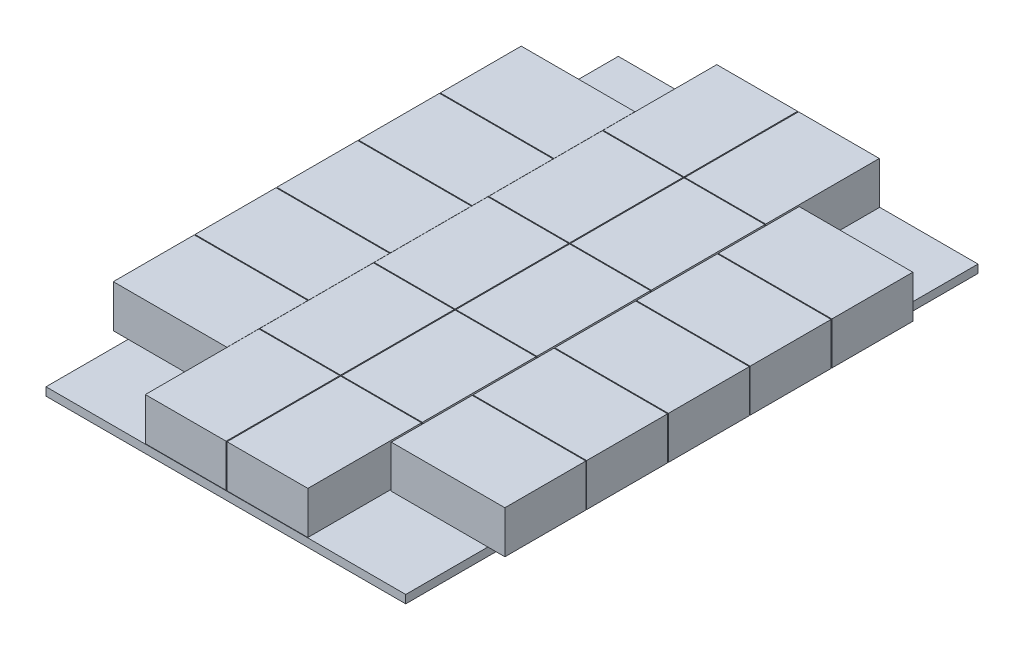
from build123d import *

# Parameters (mm, degrees)
SKETCH1_W                     = 220
SKETCH1_H                     = 350
BOSS_EXTRUDE1_DEPTH           = 5
SKETCH2_W                     = 49.4
SKETCH2_H                     = 69.5
BOSS_EXTRUDE2_DEPTH           = 26
LPATTERN1_COUNT               = 2
LPATTERN1_PITCH               = 50
LPATTERN3_COUNT               = 3
LPATTERN3_PITCH               = 70
LPATTERN3_COPY_1_SKETCH_W     = 49.4
LPATTERN3_COPY_1_SKETCH_H     = 69.5
LPATTERN3_COPY_1_DEPTH        = 26
LPATTERN3_COPY_2_SKETCH_W     = 49.4
LPATTERN3_COPY_2_SKETCH_H     = 69.5
LPATTERN3_COPY_2_DEPTH        = 26
LPATTERN3_COL_COUNT           = 3
LPATTERN3_COL_PITCH           = 70
LPATTERN3_COL_COPY_1_SKETCH_W = 49.4
LPATTERN3_COL_COPY_1_SKETCH_H = 69.5
LPATTERN3_COL_COPY_1_DEPTH    = 26
LPATTERN3_COL_COPY_2_SKETCH_W = 49.4
LPATTERN3_COL_COPY_2_SKETCH_H = 69.5
LPATTERN3_COL_COPY_2_DEPTH    = 26
SKETCH4_W                     = 69.5
SKETCH4_H                     = 49.5
BOSS_EXTRUDE3_DEPTH           = 26
LPATTERN4_COUNT               = 3
LPATTERN4_PITCH               = 50
LPATTERN4_COL_COUNT           = 3
LPATTERN4_COL_PITCH           = 50
LPATTERN5_COUNT               = 2
LPATTERN5_PITCH               = 170
LPATTERN5_COPY_1_SKETCH_W     = 69.5
LPATTERN5_COPY_1_SKETCH_H     = 49.5
LPATTERN5_COPY_1_DEPTH        = 26
LPATTERN5_COPY_2_SKETCH_W     = 69.5
LPATTERN5_COPY_2_SKETCH_H     = 49.5
LPATTERN5_COPY_2_DEPTH        = 26
LPATTERN5_COPY_3_SKETCH_W     = 69.5
LPATTERN5_COPY_3_SKETCH_H     = 49.5
LPATTERN5_COPY_3_DEPTH        = 26
LPATTERN5_COPY_4_SKETCH_W     = 69.5
LPATTERN5_COPY_4_SKETCH_H     = 49.5
LPATTERN5_COPY_4_DEPTH        = 26


with BuildPart() as part:
    # Sketch1 → Boss-Extrude1 (new body)
    with BuildSketch(Plane(origin=(0, 0, 0), x_dir=(1, 0, 0), z_dir=(0, 1, 0))):
        Rectangle(SKETCH1_W, SKETCH1_H)
    extrude(amount=BOSS_EXTRUDE1_DEPTH)

    # Sketch2 → Boss-Extrude2 (add)
    with BuildSketch(Plane(origin=(0, 5, 0), x_dir=(1, 0, 0), z_dir=(0, 1, 0))):
        with Locations((-24.8, 0)):
            Rectangle(SKETCH2_W, SKETCH2_H)
    boss_extrude2 = extrude(amount=BOSS_EXTRUDE2_DEPTH)

    # LPattern1: Boss-Extrude2 ×2
    with Locations(*[(i * LPATTERN1_PITCH, 0, 0) for i in range(1, LPATTERN1_COUNT)]):
        add(boss_extrude2)

    # LPattern3: Boss-Extrude2 ×3
    with Locations(*[(0, 0, -i * LPATTERN3_PITCH) for i in range(1, LPATTERN3_COUNT)]):
        add(boss_extrude2)

    # LPattern3 copy 1 sketch → LPattern3 copy 1 (add)
    with BuildSketch(Plane(origin=(50, 5, -70), x_dir=(1, 0, 0), z_dir=(0, 1, 0))):
        with Locations((-24.8, 0)):
            Rectangle(LPATTERN3_COPY_1_SKETCH_W, LPATTERN3_COPY_1_SKETCH_H)
    extrude(amount=LPATTERN3_COPY_1_DEPTH)

    # LPattern3 copy 2 sketch → LPattern3 copy 2 (add)
    with BuildSketch(Plane(origin=(50, 5, -140), x_dir=(1, 0, 0), z_dir=(0, 1, 0))):
        with Locations((-24.8, 0)):
            Rectangle(LPATTERN3_COPY_2_SKETCH_W, LPATTERN3_COPY_2_SKETCH_H)
    extrude(amount=LPATTERN3_COPY_2_DEPTH)

    # LPattern3 col: Boss-Extrude2 ×3
    with Locations(*[(0, 0, i * LPATTERN3_COL_PITCH) for i in range(1, LPATTERN3_COL_COUNT)]):
        add(boss_extrude2)

    # LPattern3 col copy 1 sketch → LPattern3 col copy 1 (add)
    with BuildSketch(Plane(origin=(50, 5, 70), x_dir=(1, 0, 0), z_dir=(0, 1, 0))):
        with Locations((-24.8, 0)):
            Rectangle(LPATTERN3_COL_COPY_1_SKETCH_W, LPATTERN3_COL_COPY_1_SKETCH_H)
    extrude(amount=LPATTERN3_COL_COPY_1_DEPTH)

    # LPattern3 col copy 2 sketch → LPattern3 col copy 2 (add)
    with BuildSketch(Plane(origin=(50, 5, 140), x_dir=(1, 0, 0), z_dir=(0, 1, 0))):
        with Locations((-24.8, 0)):
            Rectangle(LPATTERN3_COL_COPY_2_SKETCH_W, LPATTERN3_COL_COPY_2_SKETCH_H)
    extrude(amount=LPATTERN3_COL_COPY_2_DEPTH)

    # Sketch4 → Boss-Extrude3 (add)
    with BuildSketch(Plane(origin=(0, 5, 0), x_dir=(1, 0, 0), z_dir=(0, 1, 0))):
        with Locations((-84.35, 0)):
            Rectangle(SKETCH4_W, SKETCH4_H)
    boss_extrude3 = extrude(amount=BOSS_EXTRUDE3_DEPTH)

    # LPattern4: Boss-Extrude3 ×3
    with Locations(*[(0, 0, i * LPATTERN4_PITCH) for i in range(1, LPATTERN4_COUNT)]):
        add(boss_extrude3)

    # LPattern4 col: Boss-Extrude3 ×3
    with Locations(*[(0, 0, -i * LPATTERN4_COL_PITCH) for i in range(1, LPATTERN4_COL_COUNT)]):
        add(boss_extrude3)

    # LPattern5: Boss-Extrude3 ×2
    with Locations(*[(i * LPATTERN5_PITCH, 0, 0) for i in range(1, LPATTERN5_COUNT)]):
        add(boss_extrude3)

    # LPattern5 copy 1 sketch → LPattern5 copy 1 (add)
    with BuildSketch(Plane(origin=(170, 5, 50), x_dir=(1, 0, 0), z_dir=(0, 1, 0))):
        with Locations((-84.35, 0)):
            Rectangle(LPATTERN5_COPY_1_SKETCH_W, LPATTERN5_COPY_1_SKETCH_H)
    extrude(amount=LPATTERN5_COPY_1_DEPTH)

    # LPattern5 copy 2 sketch → LPattern5 copy 2 (add)
    with BuildSketch(Plane(origin=(170, 5, 100), x_dir=(1, 0, 0), z_dir=(0, 1, 0))):
        with Locations((-84.35, 0)):
            Rectangle(LPATTERN5_COPY_2_SKETCH_W, LPATTERN5_COPY_2_SKETCH_H)
    extrude(amount=LPATTERN5_COPY_2_DEPTH)

    # LPattern5 copy 3 sketch → LPattern5 copy 3 (add)
    with BuildSketch(Plane(origin=(170, 5, -50), x_dir=(1, 0, 0), z_dir=(0, 1, 0))):
        with Locations((-84.35, 0)):
            Rectangle(LPATTERN5_COPY_3_SKETCH_W, LPATTERN5_COPY_3_SKETCH_H)
    extrude(amount=LPATTERN5_COPY_3_DEPTH)

    # LPattern5 copy 4 sketch → LPattern5 copy 4 (add)
    with BuildSketch(Plane(origin=(170, 5, -100), x_dir=(1, 0, 0), z_dir=(0, 1, 0))):
        with Locations((-84.35, 0)):
            Rectangle(LPATTERN5_COPY_4_SKETCH_W, LPATTERN5_COPY_4_SKETCH_H)
    extrude(amount=LPATTERN5_COPY_4_DEPTH)


solid = part.part
